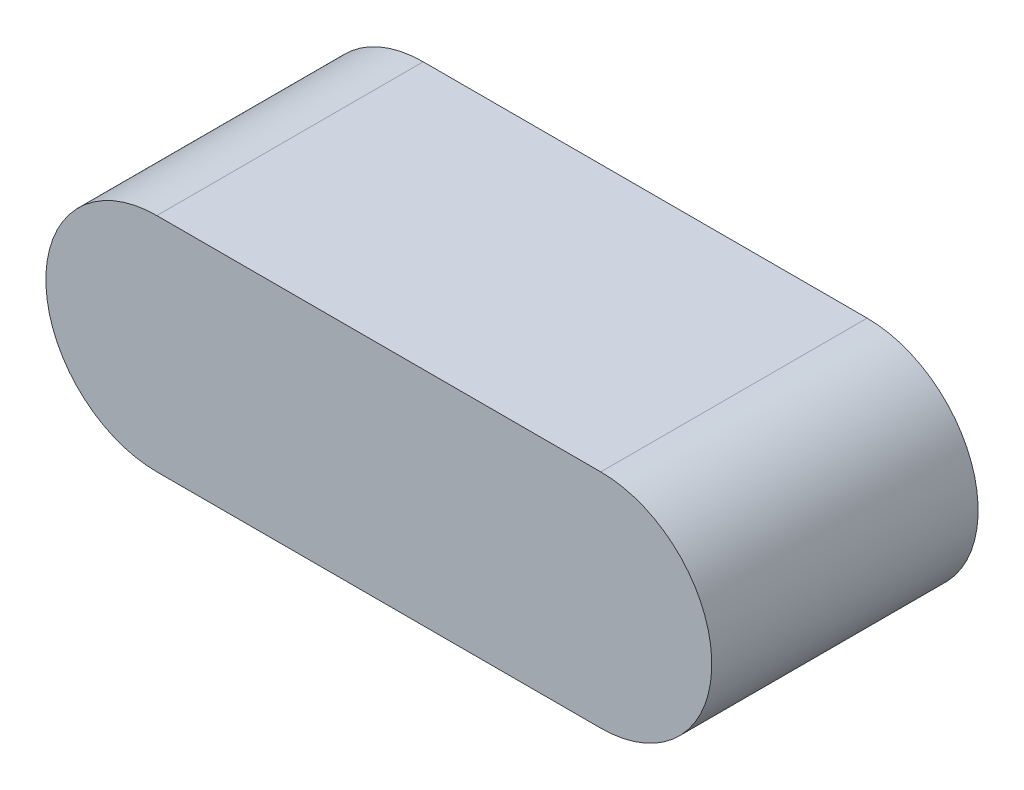
from build123d import *

# Parameters (mm, degrees)
EXTRUDE_1_DEPTH = 6


with BuildPart() as part:
    # 草图1 → 凸台-拉伸1 (new body)
    with BuildSketch(Plane.XY):
        with BuildLine():
            Line((-12.260035714, 2.5), (-2.260035714, 2.5))
            ThreePointArc((-2.260035714, 2.5), (0.239964286, 0), (-2.260035714, -2.5))
            Line((-2.260035714, -2.5), (-12.260035714, -2.5))
            ThreePointArc((-12.260035714, -2.5), (-14.760035714, 0), (-12.260035714, 2.5))
        make_face()
    extrude(amount=EXTRUDE_1_DEPTH)


solid = part.part
